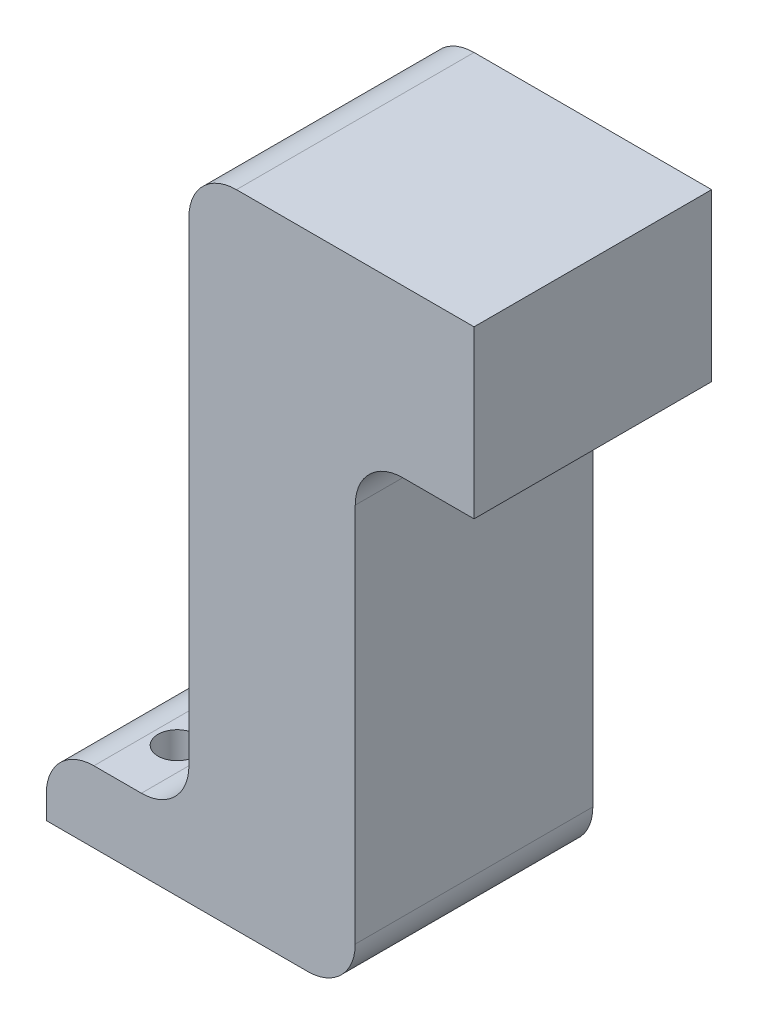
from build123d import *

# Parameters (mm, degrees)
SKETCH1_W                  = 1.5
SKETCH1_H                  = 0.75
BOSS_EXTRUDE1_DEPTH        = 1.875
BOSS_EXTRUDE1_DEPTH_BACK   = 0.625
FILLET1_R                  = 0.5
F_0_4_0_4_DIAMETER_HOLE1_D = 0.4


with BuildPart() as part:
    # Sketch1 → Boss-Extrude1 (new body, two sides)
    with BuildSketch(Plane.XY) as boss_extrude1_sk:
        Polygon((0.285769435, 0.25), (-1.464230565, 0.25), (-1.464230565, -4), (-1.464230565, -4.75), (0.285769435, -4.75), align=None)
        Polygon((-1.464230565, 2), (-1.464230565, 0.25), (0.285769435, 0.25), (1.535769435, 0.25), (1.535769435, 2), align=None)
        with Locations((-2.214230565, -4.375)):
            Rectangle(SKETCH1_W, SKETCH1_H)
    extrude(amount=BOSS_EXTRUDE1_DEPTH)
    extrude(boss_extrude1_sk.sketch, amount=-BOSS_EXTRUDE1_DEPTH_BACK)

    # Fillet1
    fillet1_edges = [part.edges().sort_by_distance(p)[0] for p in [
        (0.285769435, 0.25, 0.625),
        (-2.964230565, -4, 0.625),
        (-1.464230565, -4, 0.625),
        (0.285769435, -4.75, 0.625),
        (-1.464230565, 2, 0.625),
    ]]
    fillet(fillet1_edges, radius=FILLET1_R)

    # Ø0.4 (0.4) Diameter Hole1 (through all)
    with Locations(Plane(origin=(0, -4, 0), x_dir=(1, 0, 0), z_dir=(0, 1, 0))):
        with Locations((-2.214230565, 0), (-2.214230565, -1.25)):
            Hole(F_0_4_0_4_DIAMETER_HOLE1_D / 2)


solid = part.part
